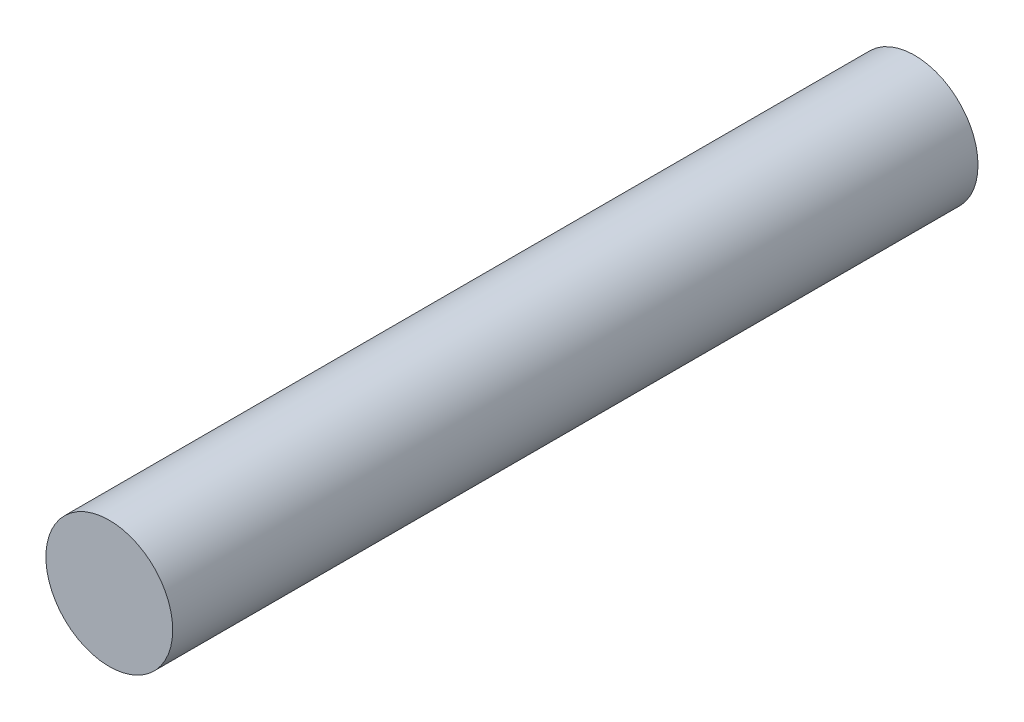
from build123d import *

# Parameters (mm, degrees)
SKETCH1_R           = 4
BOSS_EXTRUDE1_DEPTH = 50.8


with BuildPart() as part:
    # Sketch1 → Boss-Extrude1 (new body)
    with BuildSketch(Plane.XY):
        Circle(SKETCH1_R)
    extrude(amount=BOSS_EXTRUDE1_DEPTH)


solid = part.part
